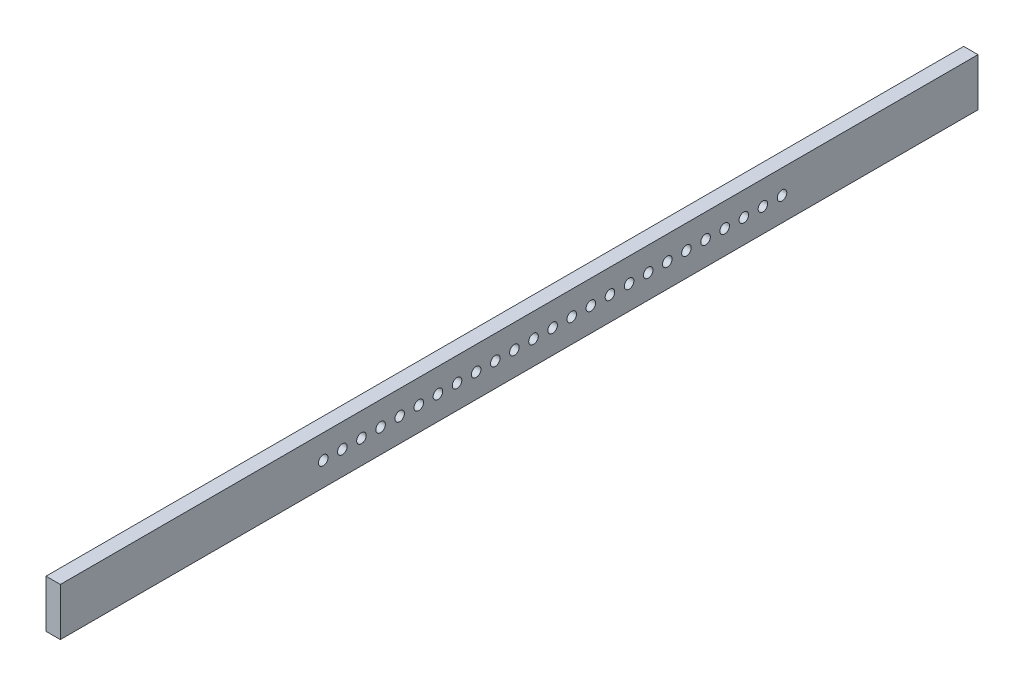
from build123d import *

# Parameters (mm, degrees)
SKETCH1_W           = 960
SKETCH1_H           = 50
SKETCH1_R           = 5
BOSS_EXTRUDE1_DEPTH = 15


with BuildPart() as part:
    # Sketch1 → Boss-Extrude1 (new body)
    with BuildSketch(Plane(origin=(0, 0, 0), x_dir=(0, 0, -1), z_dir=(1, 0, 0))):
        Rectangle(SKETCH1_W, SKETCH1_H)
        with Locations((-205, 0)):
            Circle(SKETCH1_R, mode=Mode.SUBTRACT)
        with Locations((-185, 0)):
            Circle(SKETCH1_R, mode=Mode.SUBTRACT)
        with Locations((-165, 0)):
            Circle(SKETCH1_R, mode=Mode.SUBTRACT)
        with Locations((-145, 0)):
            Circle(SKETCH1_R, mode=Mode.SUBTRACT)
        with Locations((-125, 0)):
            Circle(SKETCH1_R, mode=Mode.SUBTRACT)
        with Locations((-105, 0)):
            Circle(SKETCH1_R, mode=Mode.SUBTRACT)
        with Locations((-85, 0)):
            Circle(SKETCH1_R, mode=Mode.SUBTRACT)
        with Locations((-65, 0)):
            Circle(SKETCH1_R, mode=Mode.SUBTRACT)
        with Locations((-45, 0)):
            Circle(SKETCH1_R, mode=Mode.SUBTRACT)
        with Locations((-25, 0)):
            Circle(SKETCH1_R, mode=Mode.SUBTRACT)
        with Locations((-5, 0)):
            Circle(SKETCH1_R, mode=Mode.SUBTRACT)
        with Locations((15, 0)):
            Circle(SKETCH1_R, mode=Mode.SUBTRACT)
        with Locations((35, 0)):
            Circle(SKETCH1_R, mode=Mode.SUBTRACT)
        with Locations((55, 0)):
            Circle(SKETCH1_R, mode=Mode.SUBTRACT)
        with Locations((75, 0)):
            Circle(SKETCH1_R, mode=Mode.SUBTRACT)
        with Locations((95, 0)):
            Circle(SKETCH1_R, mode=Mode.SUBTRACT)
        with Locations((115, 0)):
            Circle(SKETCH1_R, mode=Mode.SUBTRACT)
        with Locations((135, 0)):
            Circle(SKETCH1_R, mode=Mode.SUBTRACT)
        with Locations((155, 0)):
            Circle(SKETCH1_R, mode=Mode.SUBTRACT)
        with Locations((175, 0)):
            Circle(SKETCH1_R, mode=Mode.SUBTRACT)
        with Locations((195, 0)):
            Circle(SKETCH1_R, mode=Mode.SUBTRACT)
        with Locations((215, 0)):
            Circle(SKETCH1_R, mode=Mode.SUBTRACT)
        with Locations((235, 0)):
            Circle(SKETCH1_R, mode=Mode.SUBTRACT)
        with Locations((255, 0)):
            Circle(SKETCH1_R, mode=Mode.SUBTRACT)
        with Locations((275, 0)):
            Circle(SKETCH1_R, mode=Mode.SUBTRACT)
    extrude(amount=BOSS_EXTRUDE1_DEPTH)


solid = part.part
